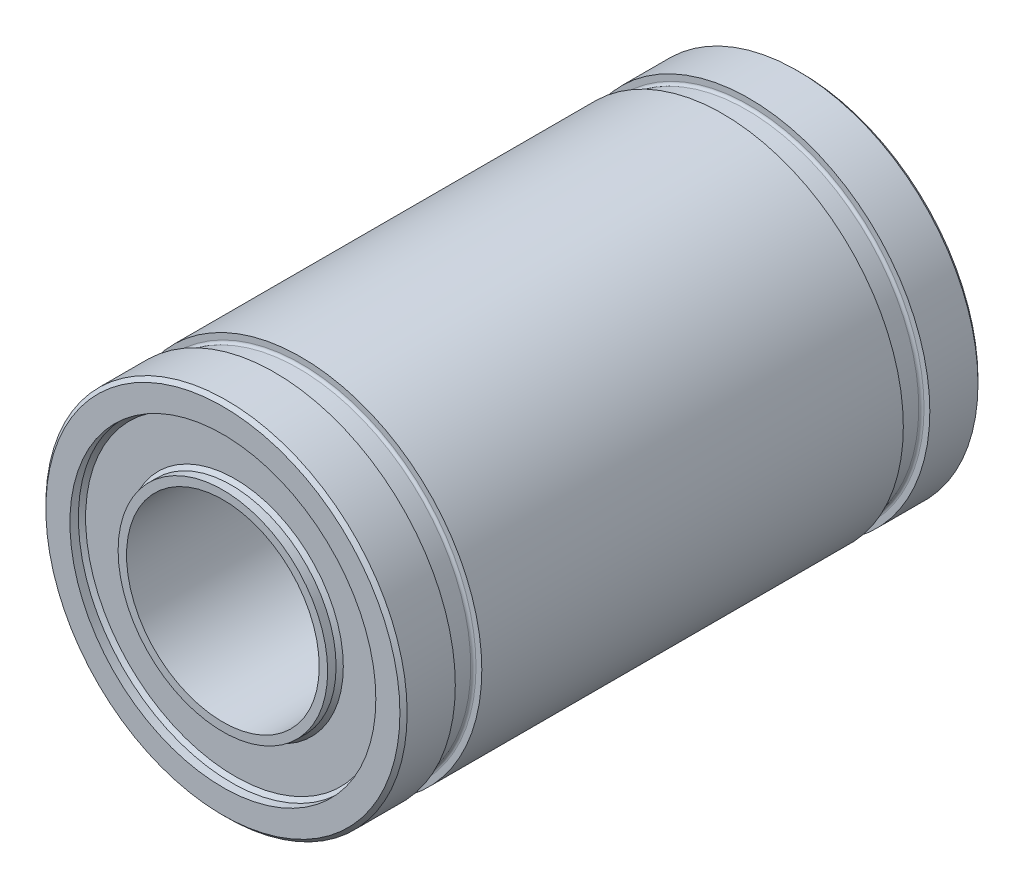
from build123d import *

# Parameters (mm, degrees)
SKETCH1_R           = 7.5
SKETCH1_R_2         = 4
BOSS_EXTRUDE1_DEPTH = 24
SKETCH2_R           = 6.35
SKETCH2_R_2         = 4.35
CUT_EXTRUDE1_DEPTH  = 0.5
SKETCH3_R           = 6.35
SKETCH3_R_2         = 4.35
CUT_EXTRUDE2_DEPTH  = 0.5
CHAMFER1_SIZE       = 0.15


with BuildPart() as part:
    # Sketch1 → Boss-Extrude1 (new body)
    with BuildSketch(Plane.XY):
        Circle(SKETCH1_R)
        Circle(SKETCH1_R_2, mode=Mode.SUBTRACT)
    extrude(amount=-BOSS_EXTRUDE1_DEPTH)

    # Sketch2 → Cut-Extrude1 (cut)
    with BuildSketch(Plane.XY):
        Circle(SKETCH2_R)
        Circle(SKETCH2_R_2, mode=Mode.SUBTRACT)
    extrude(amount=-CUT_EXTRUDE1_DEPTH, mode=Mode.SUBTRACT)

    # Sketch3 → Cut-Extrude2 (cut)
    with BuildSketch(Plane(origin=(0, 0, -24), x_dir=(-1, 0, 0), z_dir=(0, 0, -1))):
        Circle(SKETCH3_R)
        Circle(SKETCH3_R_2, mode=Mode.SUBTRACT)
    extrude(amount=-CUT_EXTRUDE2_DEPTH, mode=Mode.SUBTRACT)

    # Groove Sketch → Retaining Ring Groove (revolve, cut)
    with BuildSketch(Plane(origin=(10.524041949, 3.020841974, -25.315160673), x_dir=(-0.243952573, -0.070024633, -0.967255754), z_dir=(-0.27590078, 0.961186121, 0))):
        with BuildLine():
            Line((-16.721138463, 23.21299415), (-16.66022558, 23.445135531))
            Line((-16.66022558, 23.445135531), (-17.724206909, 23.724319577))
            Line((-17.724206909, 23.724319577), (-17.785119792, 23.492178196))
            ThreePointArc((-17.785119792, 23.492178196), (-17.773697794, 23.408766243), (-17.706640064, 23.357861658))
            Line((-17.706640064, 23.357861658), (-16.855455, 23.134514422))
            ThreePointArc((-16.855455, 23.134514422), (-16.772043048, 23.14593642), (-16.721138463, 23.21299415))
        make_face()
    revolve(axis=Axis((0, 0, -38.025873123), (0, 0, 1)), mode=Mode.SUBTRACT)

    # Groove Sketch1 → Retaining Ring Groove1 (revolve, cut)
    with BuildSketch(Plane(origin=(10.524041949, 3.020841974, -25.315160673), x_dir=(-0.243952573, -0.070024633, -0.967255754), z_dir=(-0.27590078, 0.961186121, 0))):
        with BuildLine():
            Line((1.269818557, 18.492245746), (1.33073144, 18.724387127))
            Line((1.33073144, 18.724387127), (0.266750111, 19.003571172))
            Line((0.266750111, 19.003571172), (0.205837228, 18.771429791))
            ThreePointArc((0.205837228, 18.771429791), (0.217259227, 18.688017839), (0.284316956, 18.637113254))
            Line((0.284316956, 18.637113254), (1.13550202, 18.413766017))
            ThreePointArc((1.13550202, 18.413766017), (1.218913972, 18.425188016), (1.269818557, 18.492245746))
        make_face()
    revolve(axis=Axis((0, 0, -38.025873123), (0, 0, 1)), mode=Mode.SUBTRACT)

    # Chamfer1
    chamfer1_edges = [part.edges().sort_by_distance(p)[0] for p in [
        (-6.35, 0, -0.5),
        (-4.35, 0, -0.5),
        (6.35, 0, -23.5),
        (-7.5, 0, 0),
        (4.35, 0, -23.5),
        (-7.5, 0, -24),
    ]]
    chamfer(chamfer1_edges, length=CHAMFER1_SIZE)


solid = part.part
